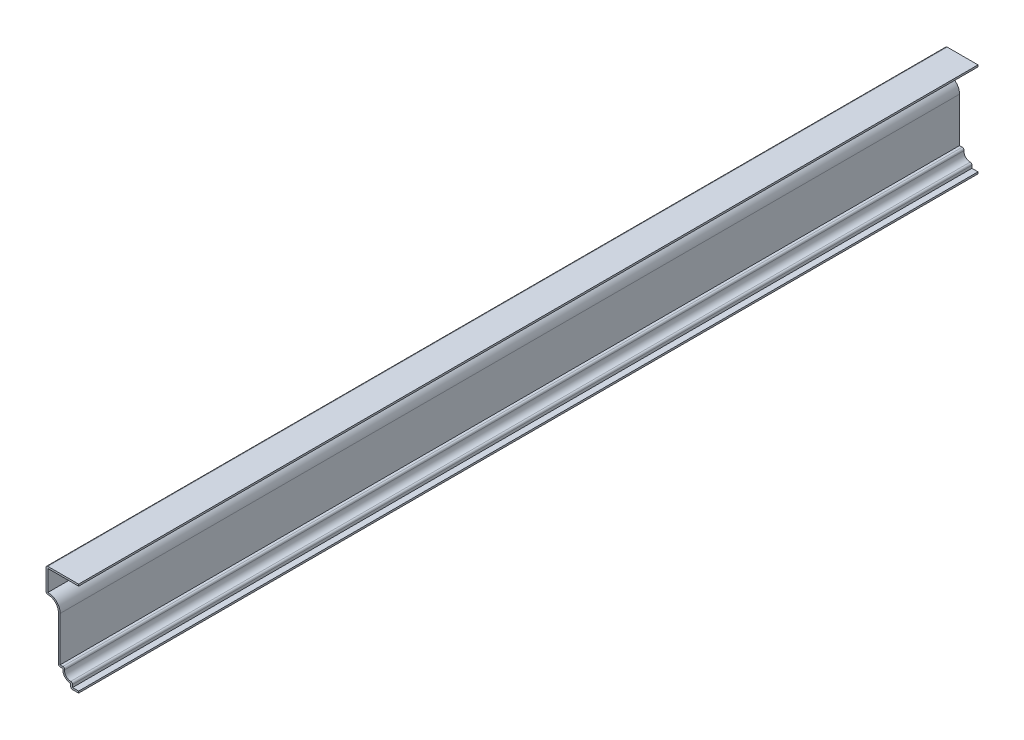
from build123d import *

# Parameters (mm, degrees)
EXTRUDE_THIN1_DEPTH = 635
FILLET1_R           = 1.27


with BuildPart() as part:
    # Sketch1 → Extrude-Thin1 (new body)
    with BuildSketch(Plane.XY):
        with BuildLine():
            Line((0, 0), (-5.55625, 0))
            Line((-5.55625, 0), (-5.55625, 3.175))
            ThreePointArc((-5.55625, 3.175), (-9.775089119, 5.089375145), (-11.1125, 9.525))
            Line((-11.1125, 9.525), (-14.2875, 9.525))
            Line((-14.2875, 9.525), (-14.2875, 42.247372018))
            ThreePointArc((-14.2875, 42.247372018), (-16.976339174, 47.831898282), (-23.01875, 49.2125))
            Line((-23.01875, 49.2125), (-23.01875, 66.675))
            Line((-23.01875, 66.675), (0, 66.675))
            Line((0, 66.675), (0, 65.405))
            Line((0, 65.405), (-21.74875, 65.405))
            Line((-21.74875, 65.405), (-21.74875, 50.655129317))
            ThreePointArc((-21.74875, 50.655129317), (-15.595162979, 48.308005429), (-13.0175, 42.247372018))
            Line((-13.0175, 42.247372018), (-13.0175, 10.795))
            Line((-13.0175, 10.795), (-9.395900253, 10.795))
            ThreePointArc((-9.395900253, 10.795), (-8.89341428, 6.012644953), (-4.28625, 4.635165643))
            Line((-4.28625, 4.635165643), (-4.28625, 1.27))
            Line((-4.28625, 1.27), (0, 1.27))
            Line((0, 1.27), (0, 0))
        make_face()
    extrude(amount=-EXTRUDE_THIN1_DEPTH)

    # Fillet1
    fillet1_edges = [part.edges().sort_by_distance(p)[0] for p in [
        (-9.395900253, 10.795, -317.5),
        (-4.28625, 4.635165643, -317.5),
        (-5.55625, 0, -317.5),
        (-14.2875, 9.525, -317.5),
        (-23.01875, 49.2125, -317.5),
        (-23.01875, 66.675, -317.5),
    ]]
    fillet(fillet1_edges, radius=FILLET1_R)


solid = part.part
